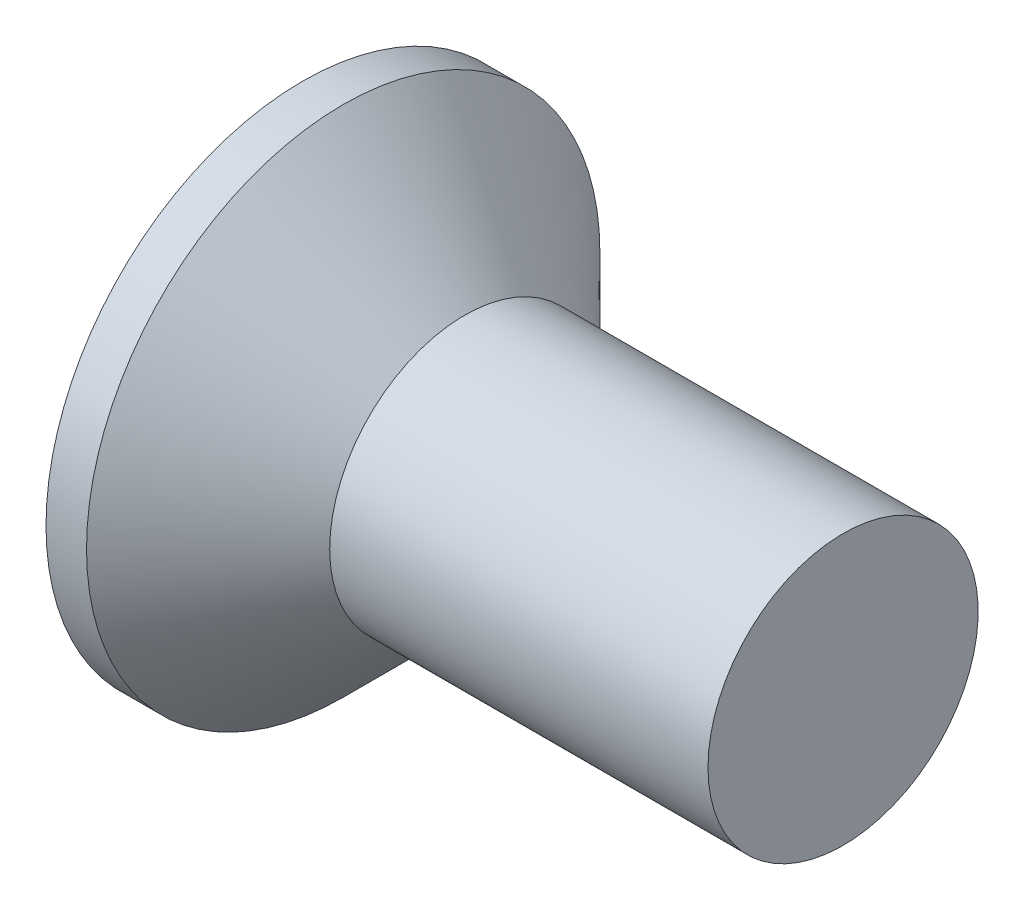
from build123d import *

# Parameters (mm, degrees)
SKETCH3_W         = 0.53
SKETCH3_H         = 2.14
SKETCH4_W         = 0.265
SKETCH4_H         = 0.265
CIRPATTERN1_COUNT = 2
CIRPATTERN1_ANGLE = 90


with BuildPart() as part:
    # BodySke → Base-Revolve (revolve)
    with BuildSketch(Plane.XY):
        Polygon((0, 0), (0, 1.9), (0.3, 1.9), (1.2, 1), (4, 1), (4, 0), align=None)
    revolve(axis=Axis((-6.35, 0, 0), (1, 0, 0)))

    # Sketch3 → Cross section 0
    with BuildSketch(Plane.ZY):
        Rectangle(SKETCH3_W, SKETCH3_H)
    # Sketch4 → Cross section 1
    with BuildSketch(Plane.ZY.offset(-1.54)):
        Rectangle(SKETCH4_W, SKETCH4_H)
    cross = loft(mode=Mode.SUBTRACT)

    # CirPattern1: Cross ×2 about axis
    cirpattern1_axis = Axis((0, 0, 0), (1, 0, 0))
    for i in range(1, CIRPATTERN1_COUNT):
        add(cross.rotate(cirpattern1_axis, i * CIRPATTERN1_ANGLE / (CIRPATTERN1_COUNT - 1)), mode=Mode.SUBTRACT)


solid = part.part
